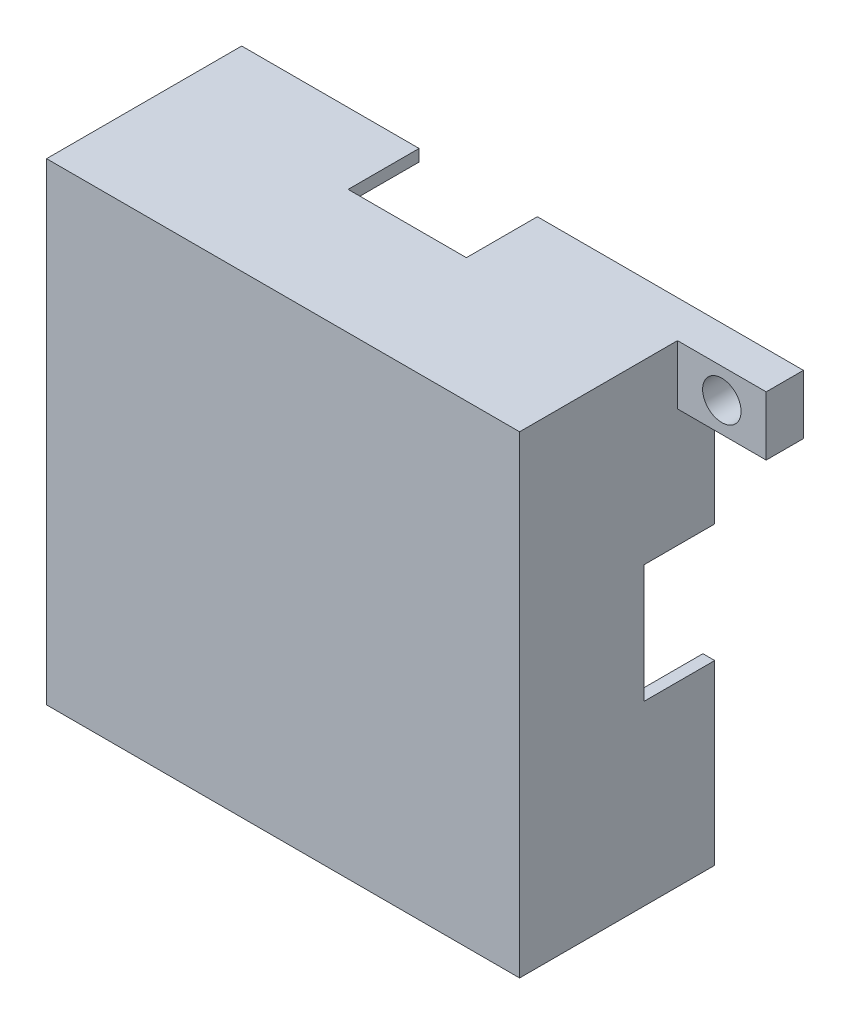
from build123d import *

# Parameters (mm, degrees)
SKETCH1_W               = 40
SKETCH1_H               = 40
SKETCH1_W_2             = 38
SKETCH1_H_2             = 38
BOSS_EXTRUDE1_DEPTH     = 15
SKETCH2_W               = 40
SKETCH2_H               = 40
BOSS_EXTRUDE2_DEPTH     = 1.5
SKETCH3_W               = 7.5
SKETCH3_H               = 5
SKETCH3_R               = 1.625
BOSS_EXTRUDE3_DEPTH     = 3.15
SKETCH4_W               = 6
SKETCH4_H               = 10
CUT_EXTRUDE1_DEPTH      = 1
CUT_EXTRUDE1_DEPTH_BACK = 48.5
SKETCH5_W               = 10
SKETCH5_H               = 6
CUT_EXTRUDE2_DEPTH      = 1
CUT_EXTRUDE2_DEPTH_BACK = 41


with BuildPart() as part:
    # Sketch1 → Boss-Extrude1 (new body)
    with BuildSketch(Plane.XY):
        with Locations((20, 20)):
            Rectangle(SKETCH1_W, SKETCH1_H)
        with Locations((20, 20)):
            Rectangle(SKETCH1_W_2, SKETCH1_H_2, mode=Mode.SUBTRACT)
    extrude(amount=BOSS_EXTRUDE1_DEPTH)

    # Sketch2 → Boss-Extrude2 (add)
    with BuildSketch(Plane.XY.offset(15)):
        with Locations((20, 20)):
            Rectangle(SKETCH2_W, SKETCH2_H)
    extrude(amount=BOSS_EXTRUDE2_DEPTH)

    # Sketch3 → Boss-Extrude3 (add)
    with BuildSketch(Plane(origin=(0, 0, 0), x_dir=(-1, 0, 0), z_dir=(0, 0, -1))):
        with Locations((-43.75, 37.5)):
            Rectangle(SKETCH3_W, SKETCH3_H)
        with Locations((-43.75, 37.5)):
            Circle(SKETCH3_R, mode=Mode.SUBTRACT)
    extrude(amount=-BOSS_EXTRUDE3_DEPTH)

    # Sketch4 → Cut-Extrude1 (cut, two sides)
    with BuildSketch(Plane.ZY) as cut_extrude1_sk:
        with Locations((3, 20)):
            Rectangle(SKETCH4_W, SKETCH4_H)
    extrude(amount=CUT_EXTRUDE1_DEPTH, mode=Mode.SUBTRACT)
    extrude(cut_extrude1_sk.sketch, amount=-CUT_EXTRUDE1_DEPTH_BACK, mode=Mode.SUBTRACT)

    # Sketch5 → Cut-Extrude2 (cut, two sides)
    with BuildSketch(Plane.XZ) as cut_extrude2_sk:
        with Locations((20, 3)):
            Rectangle(SKETCH5_W, SKETCH5_H)
    extrude(amount=CUT_EXTRUDE2_DEPTH, mode=Mode.SUBTRACT)
    extrude(cut_extrude2_sk.sketch, amount=-CUT_EXTRUDE2_DEPTH_BACK, mode=Mode.SUBTRACT)


solid = part.part
